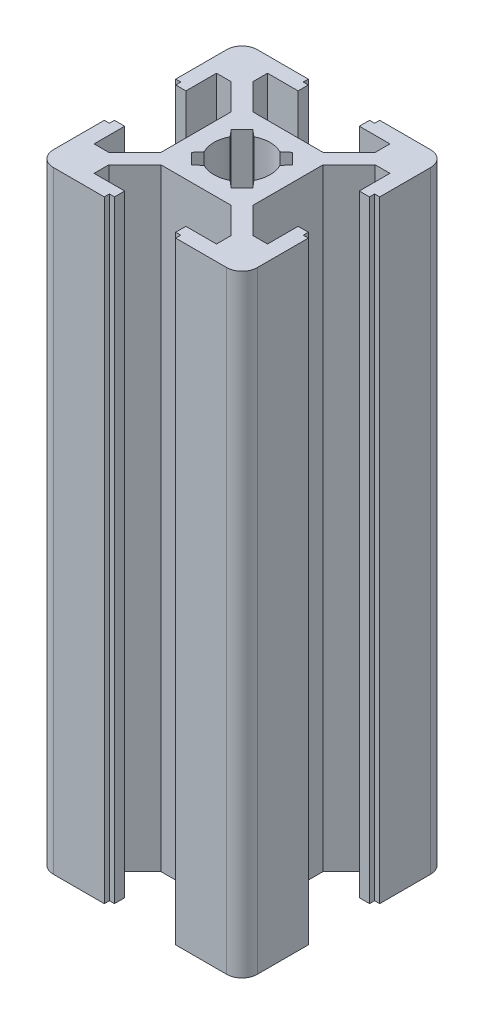
from build123d import *

# Parameters (mm, degrees)
DODANIE_WYCI_GNI_CIE1_DEPTH = 60


with BuildPart() as part:
    # Szkic1 → Dodanie-wyciągnięcie1 (new body)
    with BuildSketch(Plane(origin=(0, 0, 0), x_dir=(1, 0, 0), z_dir=(0, 1, 0))):
        with BuildLine():
            Line((-7.06, 6), (-4.5, 3.440546933))
            Line((-4.5, 3.440546933), (-4.5, 4.5))
            Line((-4.5, 4.5), (-3.440546933, 4.5))
            Line((-3.440546933, 4.5), (-6, 7.06))
            Line((-6, 7.06), (-6, 8.5))
            Line((-6, 8.5), (-3, 8.5))
            Line((-3, 8.5), (-3, 9.5))
            Line((-3, 9.5), (-3.5, 9.5))
            Line((-3.5, 9.5), (-3.5, 10))
            Line((-3.5, 10), (-8.5, 10))
            ThreePointArc((-8.5, 10), (-9.560660172, 9.560660172), (-10, 8.5))
            Line((-10, 8.5), (-10, 3.5))
            Line((-10, 3.5), (-9.5, 3.5))
            Line((-9.5, 3.5), (-9.5, 3))
            Line((-9.5, 3), (-8.5, 3))
            Line((-8.5, 3), (-8.5, 6))
            Line((-8.5, 6), (-7.06, 6))
        make_face()
        with BuildLine():
            Line((4.5, 4.5), (4.5, 3.440546933))
            Line((4.5, 3.440546933), (7.06, 6))
            Line((7.06, 6), (8.5, 6))
            Line((8.5, 6), (8.5, 3))
            Line((8.5, 3), (9.5, 3))
            Line((9.5, 3), (9.5, 3.5))
            Line((9.5, 3.5), (10, 3.5))
            Line((10, 3.5), (10, 8.5))
            ThreePointArc((10, 8.5), (9.560660172, 9.560660172), (8.5, 10))
            Line((8.5, 10), (3.5, 10))
            Line((3.5, 10), (3.5, 9.5))
            Line((3.5, 9.5), (3, 9.5))
            Line((3, 9.5), (3, 8.5))
            Line((3, 8.5), (6, 8.5))
            Line((6, 8.5), (6, 7.06))
            Line((6, 7.06), (3.440546933, 4.5))
            Line((3.440546933, 4.5), (4.5, 4.5))
        make_face()
        Polygon((3.440546933, -4.5), (4.5, -4.5), (4.5, -3.440546933), (4.5, 3.440546933), (4.5, 4.5), (3.440546933, 4.5), (-3.440546933, 4.5), (-4.5, 4.5), (-4.5, 3.440546933), (-4.5, -3.440546933), (-4.5, -4.5), (-3.440546933, -4.5), align=None)
        with BuildLine():
            Line((-3.00520382, 1.944543648), (-1.944543648, 3.00520382))
            Line((-1.944543648, 3.00520382), (-1.271309214, 2.438498079))
            ThreePointArc((-1.271309214, 2.438498079), (0, 2.75), (1.271309214, 2.438498079))
            Line((1.271309214, 2.438498079), (1.944543648, 3.00520382))
            Line((1.944543648, 3.00520382), (3.00520382, 1.944543648))
            Line((3.00520382, 1.944543648), (2.438498079, 1.271309214))
            ThreePointArc((2.438498079, 1.271309214), (2.670989491, 0.654457899), (2.75, 0))
            ThreePointArc((2.75, 0), (2.670989491, -0.654457899), (2.438498079, -1.271309214))
            Line((2.438498079, -1.271309214), (3.00520382, -1.944543648))
            Line((3.00520382, -1.944543648), (1.944543648, -3.00520382))
            Line((1.944543648, -3.00520382), (1.271309214, -2.438498079))
            ThreePointArc((1.271309214, -2.438498079), (0, -2.75), (-1.271309214, -2.438498079))
            Line((-1.271309214, -2.438498079), (-1.944543648, -3.00520382))
            Line((-1.944543648, -3.00520382), (-3.00520382, -1.944543648))
            Line((-3.00520382, -1.944543648), (-2.438498079, -1.271309214))
            ThreePointArc((-2.438498079, -1.271309214), (-2.75, 0), (-2.438498079, 1.271309214))
            Line((-2.438498079, 1.271309214), (-3.00520382, 1.944543648))
        make_face(mode=Mode.SUBTRACT)
        with BuildLine():
            Line((-6, -7.06), (-3.440546933, -4.5))
            Line((-3.440546933, -4.5), (-4.5, -4.5))
            Line((-4.5, -4.5), (-4.5, -3.440546933))
            Line((-4.5, -3.440546933), (-7.06, -6))
            Line((-7.06, -6), (-8.5, -6))
            Line((-8.5, -6), (-8.5, -3))
            Line((-8.5, -3), (-9.5, -3))
            Line((-9.5, -3), (-9.5, -3.5))
            Line((-9.5, -3.5), (-10, -3.5))
            Line((-10, -3.5), (-10, -8.5))
            ThreePointArc((-10, -8.5), (-9.560660172, -9.560660172), (-8.5, -10))
            Line((-8.5, -10), (-3.5, -10))
            Line((-3.5, -10), (-3.5, -9.5))
            Line((-3.5, -9.5), (-3, -9.5))
            Line((-3, -9.5), (-3, -8.5))
            Line((-3, -8.5), (-6, -8.5))
            Line((-6, -8.5), (-6, -7.06))
        make_face()
        with BuildLine():
            Line((4.5, -3.440546933), (4.5, -4.5))
            Line((4.5, -4.5), (3.440546933, -4.5))
            Line((3.440546933, -4.5), (6, -7.06))
            Line((6, -7.06), (6, -8.5))
            Line((6, -8.5), (3, -8.5))
            Line((3, -8.5), (3, -9.5))
            Line((3, -9.5), (3.5, -9.5))
            Line((3.5, -9.5), (3.5, -10))
            Line((3.5, -10), (8.5, -10))
            ThreePointArc((8.5, -10), (9.560660172, -9.560660172), (10, -8.5))
            Line((10, -8.5), (10, -3.5))
            Line((10, -3.5), (9.5, -3.5))
            Line((9.5, -3.5), (9.5, -3))
            Line((9.5, -3), (8.5, -3))
            Line((8.5, -3), (8.5, -6))
            Line((8.5, -6), (7.06, -6))
            Line((7.06, -6), (4.5, -3.440546933))
        make_face()
    extrude(amount=DODANIE_WYCI_GNI_CIE1_DEPTH)


solid = part.part
